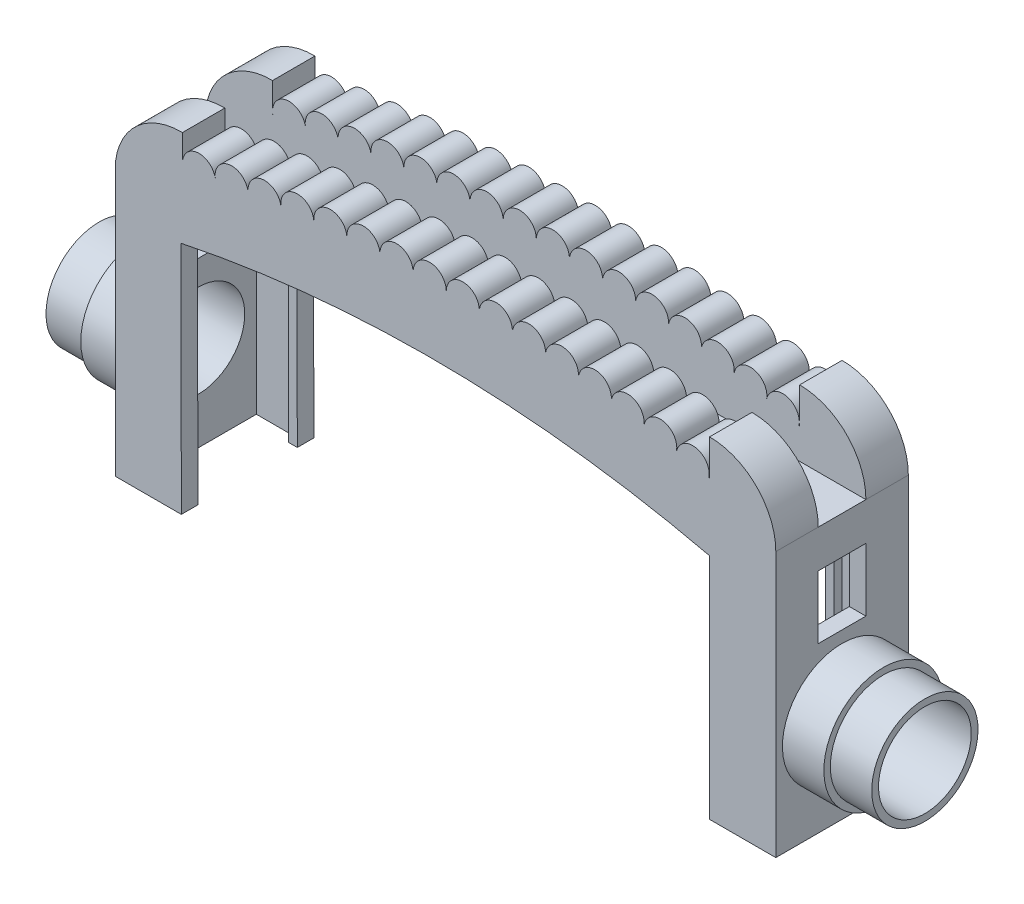
from build123d import *

# Parameters (mm, degrees)
BOSS_EXTRUDE1_DEPTH              = 12.7
SKETCH3_W                        = 4.569606656
SKETCH3_H                        = 12.610946307
CUT_EXTRUDE1_DEPTH               = 32.573497659
CUT_EXTRUDE1_DEPTH_BACK          = 32.704428158
SKETCH4_W                        = 4.569606656
SKETCH4_H                        = 6.0391821
CUT_EXTRUDE2_DEPTH               = 66.04
SKETCH5_R                        = 5.715
BOSS_EXTRUDE2_DEPTH              = 3.96875
SKETCH7_R                        = 5.09318723
BOSS_EXTRUDE3_DEPTH              = 3.96875
SKETCH9_R                        = 5.715
BOSS_EXTRUDE4_DEPTH              = 3.96875
SKETCH10_R                       = 5.08
BOSS_EXTRUDE5_DEPTH              = 3.96875
SKETCH8_R                        = 4.445
CUT_EXTRUDE4_DEPTH               = 80.152925816
CUT_EXTRUDE5_REACH               = 17.829
CUT_EXTRUDE5_OFFSET_FROM_SURFACE = 1.5875
SKETCH11_W                       = 9.525
SKETCH11_H                       = 24.345154454
SKETCH13_W                       = 9.525
SKETCH13_H                       = 22.482269966
CUT_EXTRUDE6_DEPTH               = 4.7625
CUT_EXTRUDE7_REACH               = 34.831
SKETCH14_W                       = 3.882511223
SKETCH14_H                       = 11.1125
SKETCH15_W                       = 3.945830838
SKETCH15_H                       = 11.1125
CUT_EXTRUDE8_DEPTH               = 22.48227


with BuildPart() as part:
    # Sketch1 → Boss-Extrude1 (new body)
    with BuildSketch(Plane.XY):
        with BuildLine():
            Line((25.223497659, -24.95432425), (31.573497659, -24.95432425))
            Line((31.573497659, -24.95432425), (31.573497659, 0.44567575))
            ThreePointArc((31.573497659, 0.44567575), (29.713625719, 4.935803811), (25.223497659, 6.79567575))
            Line((25.223497659, 6.79567575), (25.223497659, 3.36874218))
            ThreePointArc((25.223497659, 3.36874218), (25.194005143, 3.37526688), (25.164511033, 3.381784371))
            ThreePointArc((25.164511033, 3.381784371), (23.912297459, 5.232947026), (22.049913461, 3.997484421))
            ThreePointArc((22.049913461, 3.997484421), (20.787428344, 5.879791305), (18.929672437, 4.581449722))
            ThreePointArc((18.929672437, 4.581449722), (17.666399498, 6.401938478), (15.813867684, 5.186140916))
            ThreePointArc((15.813867684, 5.186140916), (14.370419451, 6.86745546), (12.652448322, 5.467835298))
            ThreePointArc((12.652448322, 5.467835298), (11.236710182, 7.228730664), (9.494148573, 5.790486593))
            ThreePointArc((9.494148573, 5.790486593), (8.033635968, 7.514426817), (6.328601682, 6.03188675))
            ThreePointArc((6.328601682, 6.03188675), (4.824278861, 7.717733664), (3.157897585, 6.191876393))
            ThreePointArc((3.157897585, 6.191876393), (1.610757722, 7.838516978), (-0.015870376, 6.270349895))
            ThreePointArc((-0.015870376, 6.270349895), (-1.604805836, 7.876697016), (-3.190606835, 6.267255447))
            ThreePointArc((-3.190606835, 6.267255447), (-4.820288856, 7.832248571), (-6.364215787, 6.182595092))
            ThreePointArc((-6.364215787, 6.182595092), (-8.033568431, 7.705200989), (-9.534601973, 6.016424724))
            ThreePointArc((-9.534601973, 6.016424724), (-11.24252311, 7.495638149), (-12.69967226, 5.76885405))
            ThreePointArc((-12.69967226, 5.76885405), (-14.466077033, 7.201365285), (-15.851850507, 5.398061056))
            ThreePointArc((-15.851850507, 5.398061056), (-17.628014087, 6.745603643), (-18.999984081, 4.988240156))
            ThreePointArc((-18.999984081, 4.988240156), (-20.801252814, 6.376658399), (-22.142035626, 4.539656571))
            ThreePointArc((-22.142035626, 4.539656571), (-23.987693231, 5.836740457), (-25.266933007, 3.978670437))
            ThreePointArc((-25.266933007, 3.978670437), (-25.282113604, 3.97569181), (-25.297293828, 3.972711283))
            Line((-25.297293828, 3.972711283), (-25.297293828, 6.794845101))
            ThreePointArc((-25.297293828, 6.794845101), (-29.574532825, 5.2306288), (-31.704428158, 1.205073937))
            Line((-31.704428158, 1.205073937), (-31.704428158, -24.95432425))
            Line((-31.704428158, -24.95432425), (-25.4, -24.95432425))
            Line((-25.4, -24.95432425), (-25.440666935, -2.463598833))
            ThreePointArc((-25.440666935, -2.463598833), (-0.075359426, 0.000928604), (25.223497659, -3.071619312))
            Line((25.223497659, -3.071619312), (25.223497659, -24.95432425))
        make_face()
    extrude(amount=-BOSS_EXTRUDE1_DEPTH)

    # Sketch3 → Cut-Extrude1 (cut, two sides)
    with BuildSketch(Plane(origin=(0, 0, 0), x_dir=(0, 0, -1), z_dir=(1, 0, 0))) as cut_extrude1_sk:
        with Locations((6.35, 6.751148903)):
            Rectangle(SKETCH3_W, SKETCH3_H)
    extrude(amount=CUT_EXTRUDE1_DEPTH, mode=Mode.SUBTRACT)
    extrude(cut_extrude1_sk.sketch, amount=-CUT_EXTRUDE1_DEPTH_BACK, mode=Mode.SUBTRACT)

    # Sketch4 → Cut-Extrude2 (cut)
    with BuildSketch(Plane(origin=(31.573497659, 0, 0), x_dir=(0, 0, -1), z_dir=(1, 0, 0))):
        with Locations((6.35, -6.205492883)):
            Rectangle(SKETCH4_W, SKETCH4_H)
    extrude(amount=-CUT_EXTRUDE2_DEPTH, mode=Mode.SUBTRACT)

    # Sketch5 → Boss-Extrude2 (add)
    with BuildSketch(Plane(origin=(31.573497659, 0, 0), x_dir=(0, 0, -1), z_dir=(1, 0, 0))):
        with Locations((6.35, -16.06432425)):
            Circle(SKETCH5_R)
    extrude(amount=BOSS_EXTRUDE2_DEPTH)

    # Sketch7 → Boss-Extrude3 (add)
    with BuildSketch(Plane(origin=(35.542247659, 0, 0), x_dir=(0, 0, -1), z_dir=(1, 0, 0))):
        with Locations((6.35, -16.06432425)):
            Circle(SKETCH7_R)
    extrude(amount=BOSS_EXTRUDE3_DEPTH)

    # Sketch9 → Boss-Extrude4 (add)
    with BuildSketch(Plane.ZY.offset(31.704428158)):
        with Locations((-6.35, -16.06432425)):
            Circle(SKETCH9_R)
    extrude(amount=BOSS_EXTRUDE4_DEPTH)

    # Sketch10 → Boss-Extrude5 (add)
    with BuildSketch(Plane.ZY.offset(35.673178158)):
        with Locations((-6.35, -16.06432425)):
            Circle(SKETCH10_R)
    extrude(amount=BOSS_EXTRUDE5_DEPTH)

    # Sketch8 → Cut-Extrude4 (cut, through all)
    with BuildSketch(Plane(origin=(39.510997659, 0, 0), x_dir=(0, 0, -1), z_dir=(1, 0, 0))):
        with Locations((6.35, -16.06432425)):
            Circle(SKETCH8_R)
    extrude(amount=-CUT_EXTRUDE4_DEPTH, mode=Mode.SUBTRACT)

    # Cut-Extrude5: up to this face of the body (flat: up to its plane, moved by the offset)
    cut_extrude5_end = Plane(part.part.faces().sort_by_distance((-31.704428158, -11.874625156, -0.290792729))[0]).offset(-CUT_EXTRUDE5_OFFSET_FROM_SURFACE)
    # Sketch11 → Cut-Extrude5 (cut, up to the picked face)
    with BuildSketch(Plane(origin=(-25.445038336, -0.046008819, 0), x_dir=(0, 0, -1), z_dir=(0.999998365, 0.001808162, 0)), mode=Mode.PRIVATE) as cut_extrude5_sk1:
        with Locations((6.35, -14.590171194)):
            Rectangle(SKETCH11_W, SKETCH11_H)
    cut_extrude5_tool1 = split(extrude(cut_extrude5_sk1.sketch, amount=-CUT_EXTRUDE5_REACH, mode=Mode.PRIVATE), bisect_by=cut_extrude5_end, keep=Keep.BOTH, mode=Mode.PRIVATE)
    add(cut_extrude5_tool1.solids().sort_by_distance((-25.418657, -14.636156, -6.35))[0], mode=Mode.SUBTRACT)

    # Sketch13 → Cut-Extrude6 (cut)
    with BuildSketch(Plane.ZY.offset(-25.223497659)):
        with Locations((-6.35, -13.713189267)):
            Rectangle(SKETCH13_W, SKETCH13_H)
    extrude(amount=-CUT_EXTRUDE6_DEPTH, mode=Mode.SUBTRACT)

    # Cut-Extrude7: up to this face of the body (flat: up to its plane)
    cut_extrude7_end = Plane(part.part.faces().sort_by_distance((-27.778797546, -2.467826558, -6.35))[0])
    # Sketch14 → Cut-Extrude7 (cut, up to the picked face)
    with BuildSketch(Plane.XZ.offset(24.95432425), mode=Mode.PRIVATE) as cut_extrude7_sk1:
        with Locations((-28.175672547, -6.35)):
            Rectangle(SKETCH14_W, SKETCH14_H)
    cut_extrude7_tool1 = split(extrude(cut_extrude7_sk1.sketch, amount=-CUT_EXTRUDE7_REACH, mode=Mode.PRIVATE), bisect_by=cut_extrude7_end, keep=Keep.BOTH, mode=Mode.PRIVATE)
    add(cut_extrude7_tool1.solids().sort_by_distance((-28.175673, -24.954324, -6.35))[0], mode=Mode.SUBTRACT)

    # Sketch15 → Cut-Extrude8 (cut)
    with BuildSketch(Plane.XZ.offset(24.95432425)):
        with Locations((27.990163078, -6.35)):
            Rectangle(SKETCH15_W, SKETCH15_H)
    extrude(amount=-CUT_EXTRUDE8_DEPTH, mode=Mode.SUBTRACT)


solid = part.part
